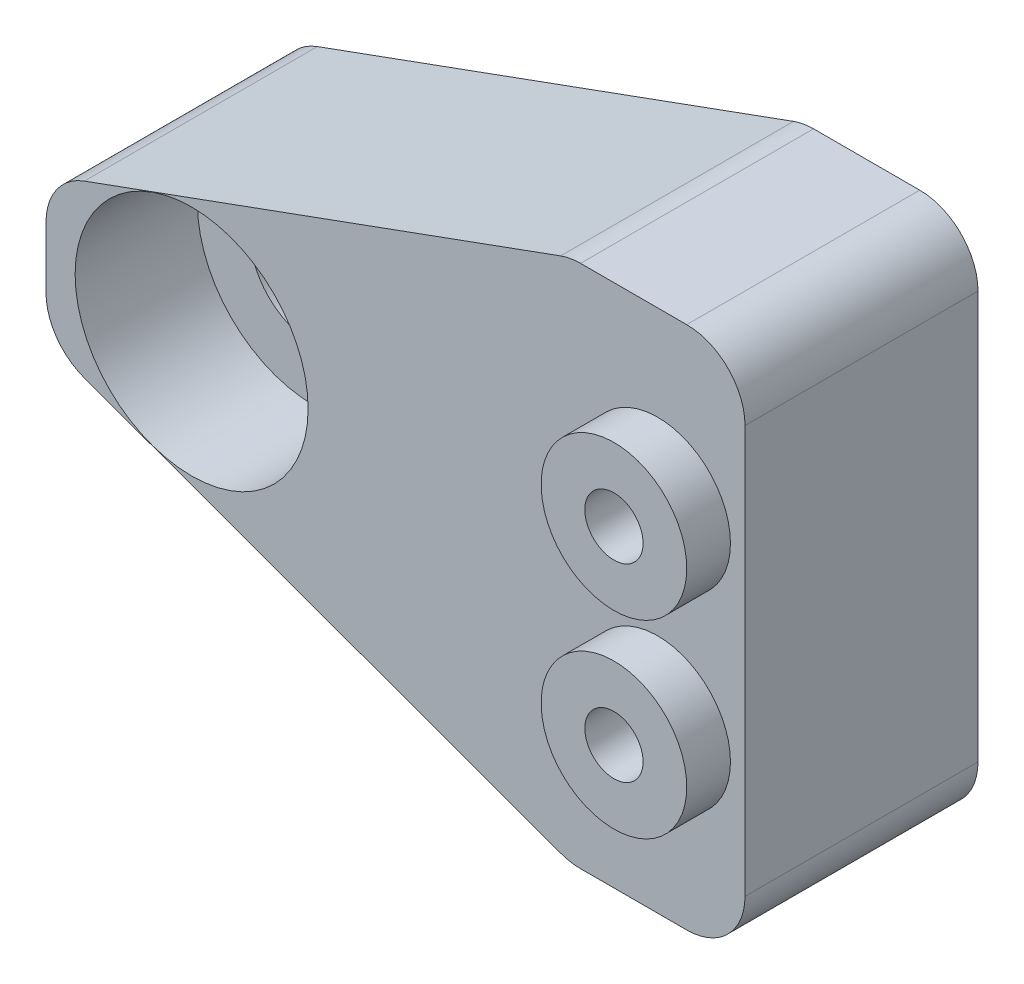
from build123d import *

# Parameters (mm, degrees)
ESQUISSE1_W             = 24
ESQUISSE1_H             = 18
BOSS_EXTRU_1_DEPTH      = 8
ESQUISSE2_R             = 2.2
ENL_V_MAT_EXTRU_1_DEPTH = 9
ESQUISSE3_R             = 4
ENL_V_MAT_EXTRU_2_DEPTH = 4.2
ESQUISSE4_R             = 1
ENL_V_MAT_EXTRU_3_DEPTH = 9
ESQUISSE5_R             = 2.6
ENL_V_MAT_EXTRU_6_DEPTH = 4.2
ESQUISSE6_R             = 1.7
BOSS_EXTRU_2_DEPTH      = 1
CHANFREIN1_SIZE         = 18
CHANFREIN1_SIZE2        = 6.551464217
CHANFREIN1_PART_2_SIZE  = 18
CHANFREIN1_PART_2_SIZE2 = 6.551464217
CONG_1_R                = 2
ESQUISSE7_R             = 2.5
ESQUISSE7_R_2           = 1
BOSS_EXTRU_3_DEPTH      = 1.5


with BuildPart() as part:
    # Esquisse1 → Boss.-Extru.1 (new body)
    with BuildSketch(Plane.XY):
        with Locations((4, 0)):
            Rectangle(ESQUISSE1_W, ESQUISSE1_H)
    extrude(amount=BOSS_EXTRU_1_DEPTH)

    # Esquisse2 → Enlèv. mat.-Extru.1 (cut, through all)
    with BuildSketch(Plane.XY.offset(8)):
        with Locations((-3, 0)):
            Circle(ESQUISSE2_R)
    extrude(amount=-ENL_V_MAT_EXTRU_1_DEPTH, mode=Mode.SUBTRACT)

    # Esquisse3 → Enlèv. mat.-Extru.2 (cut)
    with BuildSketch(Plane.XY.offset(8)):
        with Locations((-3, 0)):
            Circle(ESQUISSE3_R)
    extrude(amount=-ENL_V_MAT_EXTRU_2_DEPTH, mode=Mode.SUBTRACT)

    # Esquisse4 → Enlèv. mat.-Extru.3 (cut, through all)
    with BuildSketch(Plane.XY.offset(8)):
        with Locations((13, 3.25)):
            Circle(ESQUISSE4_R)
        with Locations((13, -3.25)):
            Circle(ESQUISSE4_R)
    extrude(amount=-ENL_V_MAT_EXTRU_3_DEPTH, mode=Mode.SUBTRACT)

    # Esquisse5 → Enlèv. mat.-Extru.6 (cut)
    with BuildSketch(Plane(origin=(0, 0, 0), x_dir=(-1, 0, 0), z_dir=(0, 0, -1))):
        with Locations((-13, 3.25)):
            Circle(ESQUISSE5_R)
        with Locations((-13, -3.25)):
            Circle(ESQUISSE5_R)
    extrude(amount=-ENL_V_MAT_EXTRU_6_DEPTH, mode=Mode.SUBTRACT)

    # Esquisse6 → Boss.-Extru.2 (add)
    with BuildSketch(Plane(origin=(0, 0, 4.2), x_dir=(-1, 0, 0), z_dir=(0, 0, -1))):
        with Locations((-13, 3.25)):
            Circle(ESQUISSE6_R)
        with Locations((-13, -3.25)):
            Circle(ESQUISSE6_R)
    extrude(amount=-BOSS_EXTRU_2_DEPTH)

    # Chanfrein1
    chanfrein1_edges = [part.edges().sort_by_distance(p)[0] for p in [
        (-8, 9, 4),
    ]]
    chanfrein1_side = [part.faces().sort_by_distance(p)[0] for p in [
        (4, 9, 4),
    ]]
    chamfer(chanfrein1_edges, length=CHANFREIN1_SIZE, length2=CHANFREIN1_SIZE2, reference=chanfrein1_side[0])

    # Chanfrein1 part 2
    chanfrein1_part_2_edges = [part.edges().sort_by_distance(p)[0] for p in [
        (-8, -9, 4),
    ]]
    chanfrein1_part_2_side = [part.faces().sort_by_distance(p)[0] for p in [
        (4, -9, 4),
    ]]
    chamfer(chanfrein1_part_2_edges, length=CHANFREIN1_PART_2_SIZE, length2=CHANFREIN1_PART_2_SIZE2, reference=chanfrein1_part_2_side[0])

    # Congé1
    cong_1_edges = [part.edges().sort_by_distance(p)[0] for p in [
        (10, -9, 4),
        (-8, 2.448535783, 4),
        (-8, -2.448535783, 4),
        (10, 9, 4),
        (16, 9, 4),
        (16, -9, 4),
    ]]
    fillet(cong_1_edges, radius=CONG_1_R)

    # Esquisse7 → Boss.-Extru.3 (add)
    with BuildSketch(Plane.XY.offset(8)):
        with Locations((13, -3.25)):
            Circle(ESQUISSE7_R)
        with Locations((13, -3.25)):
            Circle(ESQUISSE7_R_2, mode=Mode.SUBTRACT)
        with Locations((13, 3.25)):
            Circle(ESQUISSE7_R)
        with Locations((13, 3.25)):
            Circle(ESQUISSE7_R_2, mode=Mode.SUBTRACT)
    extrude(amount=BOSS_EXTRU_3_DEPTH)


solid = part.part
